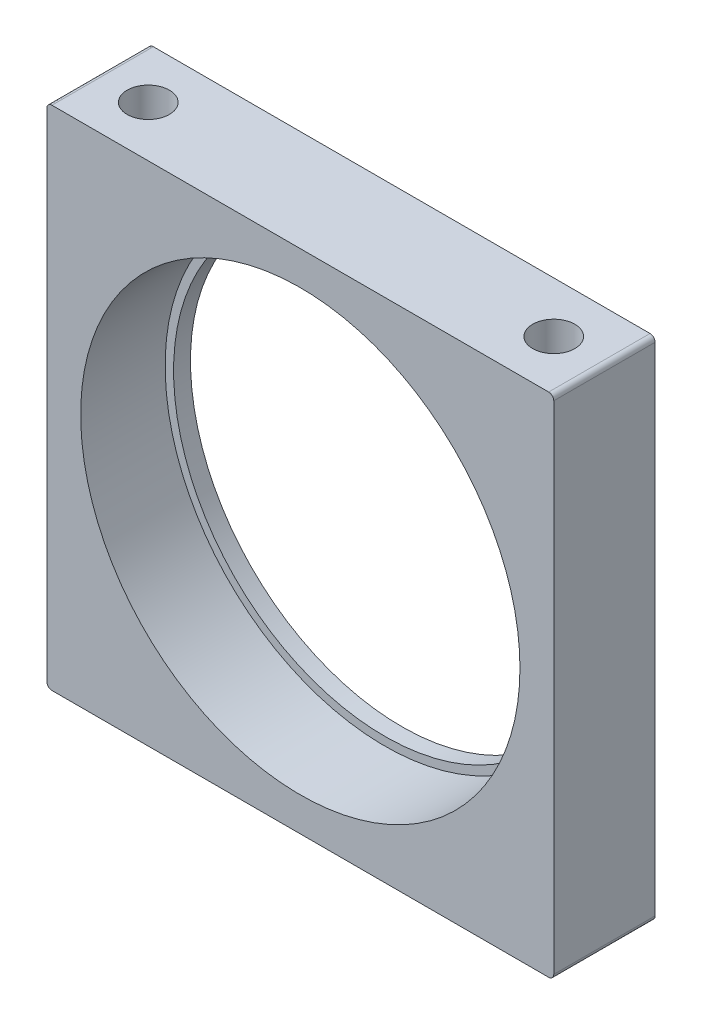
from build123d import *

# Parameters (mm, degrees)
ESQUISSE1_W                                   = 30
ESQUISSE1_H                                   = 30
ESQUISSE1_R                                   = 12.5
BOSS_EXTRU_1_DEPTH                            = 6
ESQUISSE3_R                                   = 13
ENL_V_MAT_EXTRU_1_DEPTH                       = 5
TROU_POUR_TARAUDAGE_POUR_TROU_TARAUD_M3_D     = 2.5
TROU_POUR_TARAUDAGE_POUR_TROU_TARAUD_M3_DEPTH = 6
TROU_POUR_TARAUDAGE_POUR_TROU_TARAUD_M3_TIP   = 0.751075774
TROU_POUR_TARAUDAGE_POUR_TROU_TARAUD_2_D      = 2.5
TROU_POUR_TARAUDAGE_POUR_TROU_TARAUD_2_DEPTH  = 6
TROU_POUR_TARAUDAGE_POUR_TROU_TARAUD_2_TIP    = 0.751075774
CONG_1_R                                      = 0.3


with BuildPart() as part:
    # Esquisse1 → Boss.-Extru.1 (new body)
    with BuildSketch(Plane.XY):
        with Locations((15, 15)):
            Rectangle(ESQUISSE1_W, ESQUISSE1_H)
        with Locations((15, 15)):
            Circle(ESQUISSE1_R, mode=Mode.SUBTRACT)
    extrude(amount=BOSS_EXTRU_1_DEPTH)

    # Esquisse3 → Enlèv. mat.-Extru.1 (cut)
    with BuildSketch(Plane.XY.offset(6)):
        with Locations((15, 15)):
            Circle(ESQUISSE3_R)
    extrude(amount=-ENL_V_MAT_EXTRU_1_DEPTH, mode=Mode.SUBTRACT)

    # Trou pour taraudage pour trou taraud_ M3
    with Locations(Plane(origin=(0, 30, 0), x_dir=(1, 0, 0), z_dir=(0, 1, 0))):
        with Locations((3, -3), (27, -3)):
            Hole(TROU_POUR_TARAUDAGE_POUR_TROU_TARAUD_M3_D / 2, depth=TROU_POUR_TARAUDAGE_POUR_TROU_TARAUD_M3_DEPTH)
            with Locations((0, 0, -(TROU_POUR_TARAUDAGE_POUR_TROU_TARAUD_M3_DEPTH + TROU_POUR_TARAUDAGE_POUR_TROU_TARAUD_M3_TIP / 2))):  # 118° drill point
                Cone(0, TROU_POUR_TARAUDAGE_POUR_TROU_TARAUD_M3_D / 2, TROU_POUR_TARAUDAGE_POUR_TROU_TARAUD_M3_TIP, mode=Mode.SUBTRACT)

    # Trou pour taraudage pour trou taraud 2
    with Locations(Plane(origin=(0, 0, 0), x_dir=(-1, 0, 0), z_dir=(0, -1, 0))):
        with Locations((-3, -3), (-27, -3)):
            Hole(TROU_POUR_TARAUDAGE_POUR_TROU_TARAUD_2_D / 2, depth=TROU_POUR_TARAUDAGE_POUR_TROU_TARAUD_2_DEPTH)
            with Locations((0, 0, -(TROU_POUR_TARAUDAGE_POUR_TROU_TARAUD_2_DEPTH + TROU_POUR_TARAUDAGE_POUR_TROU_TARAUD_2_TIP / 2))):  # 118° drill point
                Cone(0, TROU_POUR_TARAUDAGE_POUR_TROU_TARAUD_2_D / 2, TROU_POUR_TARAUDAGE_POUR_TROU_TARAUD_2_TIP, mode=Mode.SUBTRACT)

    # Congé1
    cong_1_edges = [part.edges().sort_by_distance(p)[0] for p in [
        (0, 30, 3),
        (30, 30, 3),
        (30, 0, 3),
        (0, 0, 3),
    ]]
    fillet(cong_1_edges, radius=CONG_1_R)


solid = part.part
